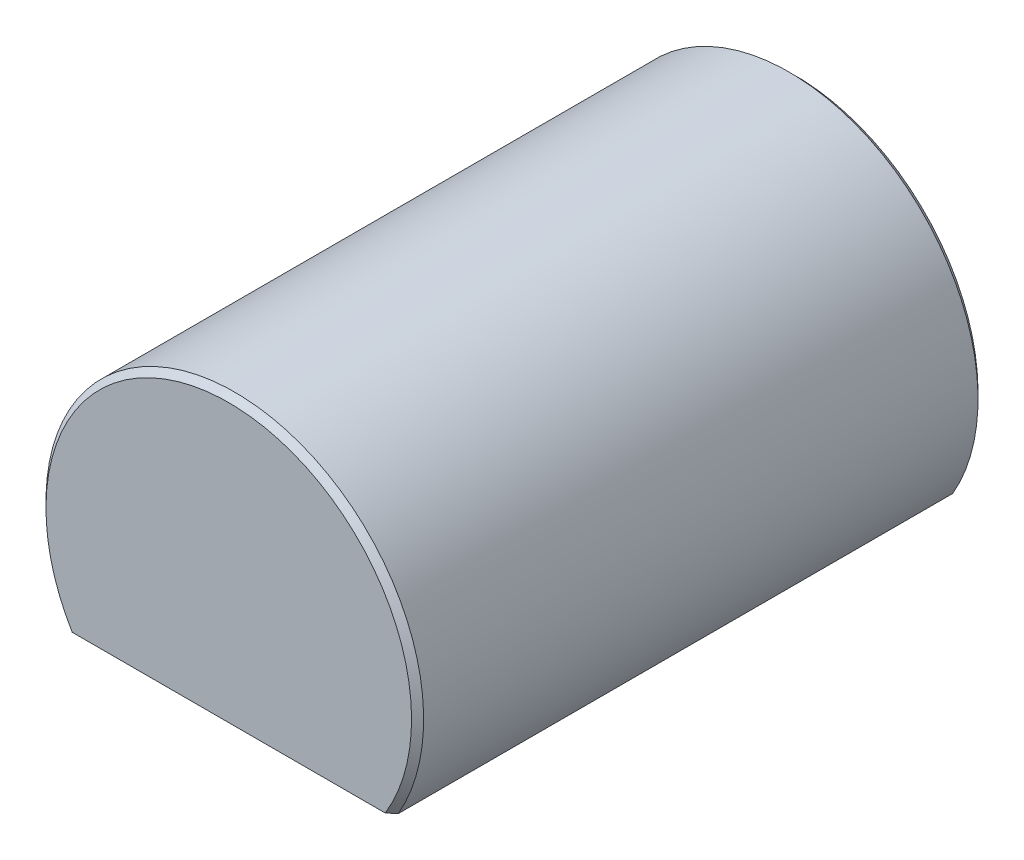
from build123d import *

# Parameters (mm, degrees)
SKETCH1_R            = 12.7
EXTRUDE1_DEPTH       = 19.05
CHAMFER1_SIZE        = 0.4064
TRUNCATED_DEPTH      = 20.05
TRUNCATED_DEPTH_BACK = 20.05
RECESSED_DEPTH       = 0.127


with BuildPart() as part:
    # Sketch1 → Extrude1 (new body, symmetric)
    with BuildSketch(Plane.XY):
        Circle(SKETCH1_R)
    extrude(amount=EXTRUDE1_DEPTH, both=True)

    # Chamfer1
    chamfer1_edges = [part.edges().sort_by_distance(p)[0] for p in [
        (-12.7, 0, -19.05),
        (-12.7, 0, 19.05),
    ]]
    chamfer(chamfer1_edges, length=CHAMFER1_SIZE)

    # Sketch2 → Truncated (cut, two sides)
    with BuildSketch(Plane.XY) as truncated_sk:
        with BuildLine():
            Line((-10.998522628, -6.35), (10.998522628, -6.35))
            ThreePointArc((10.998522628, -6.35), (0, -12.7), (-10.998522628, -6.35))
        make_face()
    extrude(amount=TRUNCATED_DEPTH, mode=Mode.SUBTRACT)
    extrude(truncated_sk.sketch, amount=-TRUNCATED_DEPTH_BACK, mode=Mode.SUBTRACT)

    # Sketch3 → Recessed (cut)
    with BuildSketch(Plane.XZ.offset(6.35)):
        with BuildLine():
            Line((7.315522628, 15.875), (-7.315522628, 15.875))
            ThreePointArc((-7.315522628, 15.875), (-7.674732873, 15.726210245), (-7.823522628, 15.367))
            Line((-7.823522628, 15.367), (-7.823522628, -15.367))
            ThreePointArc((-7.823522628, -15.367), (-7.674732873, -15.726210245), (-7.315522628, -15.875))
            Line((-7.315522628, -15.875), (7.315522628, -15.875))
            ThreePointArc((7.315522628, -15.875), (7.674732873, -15.726210245), (7.823522628, -15.367))
            Line((7.823522628, -15.367), (7.823522628, 15.367))
            ThreePointArc((7.823522628, 15.367), (7.674732873, 15.726210245), (7.315522628, 15.875))
        make_face()
    extrude(amount=-RECESSED_DEPTH, mode=Mode.SUBTRACT)


solid = part.part
